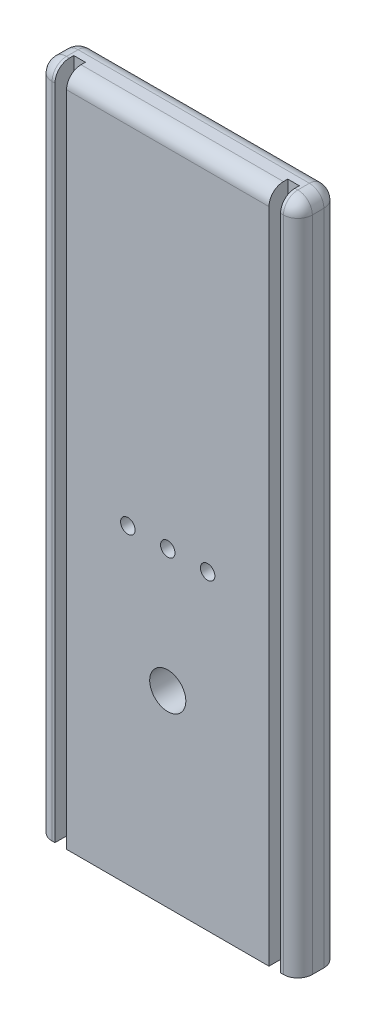
from build123d import *

# Parameters (mm, degrees)
SKETCH1_W           = 114.3
SKETCH1_H           = 295.275
BOSS_EXTRUDE1_DEPTH = 8.89
SKETCH2_R           = 3.175
CUT_EXTRUDE1_DEPTH  = 12.7
SKETCH3_W           = 5.08
SKETCH3_H           = 8.255
CUT_EXTRUDE2_DEPTH  = 296.275
FILLET1_R           = 6.35
SKETCH5_R           = 7.9375
CUT_EXTRUDE4_DEPTH  = 18.78


with BuildPart() as part:
    # Sketch1 → Boss-Extrude1 (new body, symmetric)
    with BuildSketch(Plane.XY):
        Rectangle(SKETCH1_W, SKETCH1_H)
    extrude(amount=BOSS_EXTRUDE1_DEPTH, both=True)

    # Sketch2 → Cut-Extrude1 (cut)
    with BuildSketch(Plane.XY.offset(8.89)):
        with Locations((0, -11.1125)):
            Circle(SKETCH2_R)
        with Locations((-17.526, -11.1125)):
            Circle(SKETCH2_R)
        with Locations((17.526, -11.1125)):
            Circle(SKETCH2_R)
    extrude(amount=-CUT_EXTRUDE1_DEPTH, mode=Mode.SUBTRACT)

    # Sketch3 → Cut-Extrude2 (cut, through all)
    with BuildSketch(Plane(origin=(0, 147.6375, 0), x_dir=(1, 0, 0), z_dir=(0, 1, 0))):
        with Locations((-46.99, -4.7625)):
            Rectangle(SKETCH3_W, SKETCH3_H)
    cut_extrude2 = extrude(amount=-CUT_EXTRUDE2_DEPTH, mode=Mode.SUBTRACT)

    # Mirror1: Cut-Extrude2 across plane
    add(cut_extrude2.mirror(Plane(origin=(0, 0, 0), x_dir=(0, 0, 1), z_dir=(1, 0, 0))), mode=Mode.SUBTRACT)

    # Fillet1
    fillet1_edges = [part.edges().sort_by_distance(p)[0] for p in [
        (-57.15, 0, 8.89),
        (-53.34, 147.6375, 8.89),
        (57.15, 0, 8.89),
        (0, 147.6375, 8.89),
        (-57.15, 0, -8.89),
        (0, 147.6375, -8.89),
        (57.15, 0, -8.89),
        (53.34, 147.6375, 8.89),
        (-57.15, 147.6375, 0),
        (57.15, 147.6375, 0),
    ]]
    fillet(fillet1_edges, radius=FILLET1_R)

    # Sketch5 → Cut-Extrude4 (cut, through all)
    with BuildSketch(Plane.XY.offset(8.89)):
        with Locations((0, -65.0875)):
            Circle(SKETCH5_R)
    extrude(amount=-CUT_EXTRUDE4_DEPTH, mode=Mode.SUBTRACT)


solid = part.part
